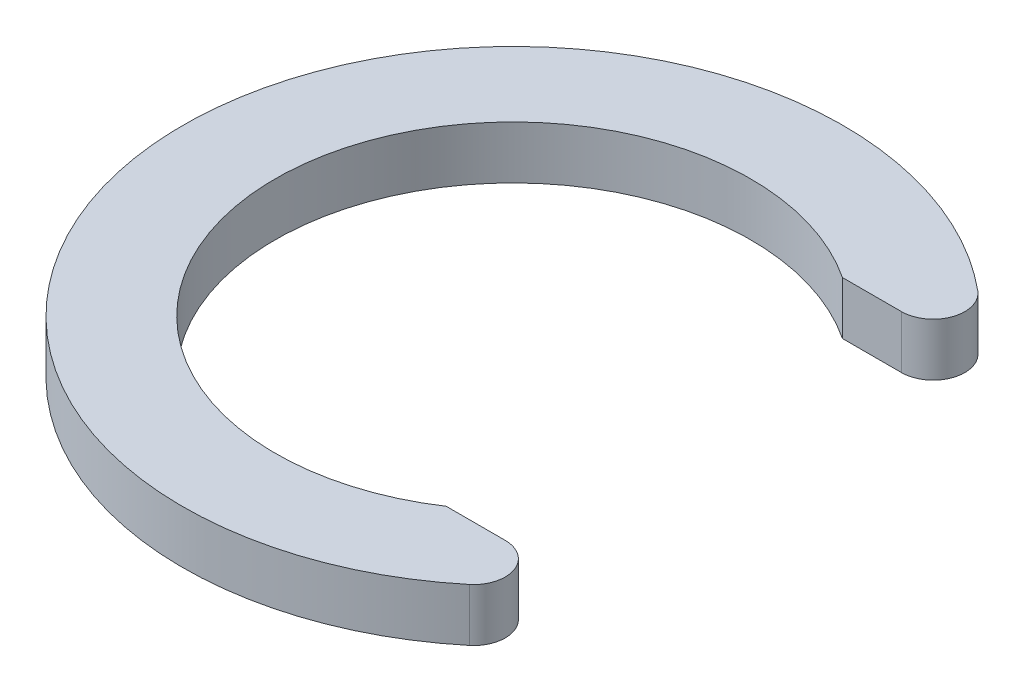
from build123d import *

# Parameters (mm, degrees)
BOSS_EXTRUDE2_DEPTH = 2
FILLET1_R           = 1.2


with BuildPart() as part:
    # Sketch1 → Boss-Extrude2 (new body)
    with BuildSketch(Plane(origin=(0, 0, 0), x_dir=(1, 0, 0), z_dir=(0, 1, 0))):
        with BuildLine():
            Line((4.974937186, 7.5), (10, 7.5))
            ThreePointArc((10, 7.5), (-12.5, 0), (10, -7.5))
            Line((10, -7.5), (4.974937186, -7.5))
            ThreePointArc((4.974937186, -7.5), (-9, 0), (4.974937186, 7.5))
        make_face()
    extrude(amount=BOSS_EXTRUDE2_DEPTH)

    # Fillet1
    fillet1_edges = [part.edges().sort_by_distance(p)[0] for p in [
        (10, 1, 7.5),
        (10, 1, -7.5),
    ]]
    fillet(fillet1_edges, radius=FILLET1_R)


solid = part.part
